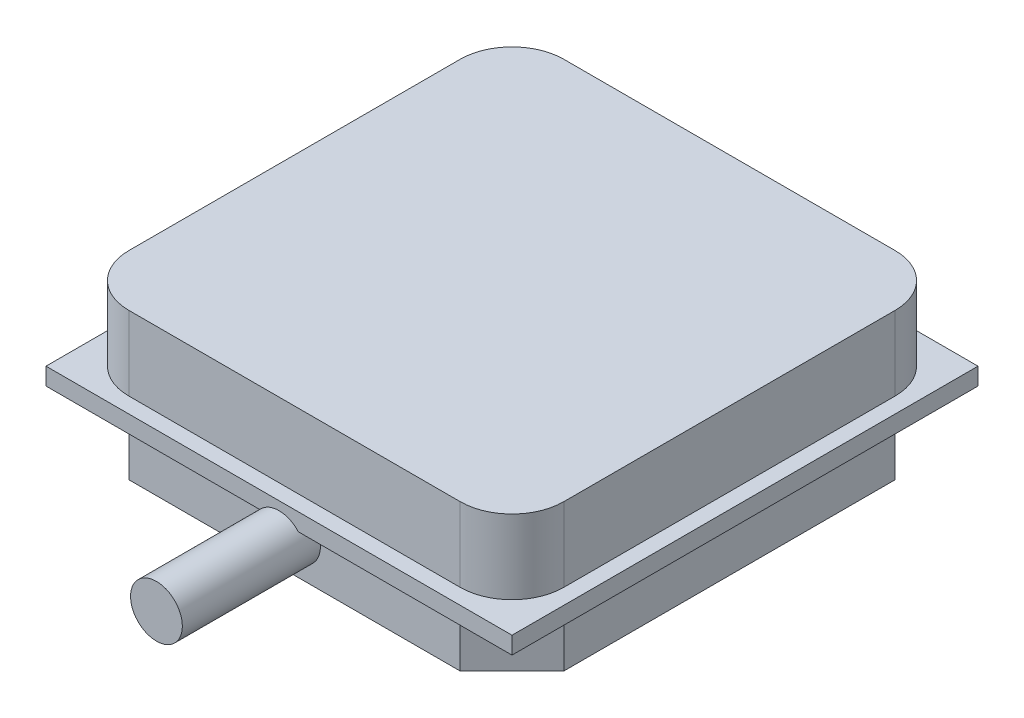
from build123d import *

# Parameters (mm, degrees)
SKETCH1_W           = 27
SKETCH1_H           = 27
BOSS_EXTRUDE1_DEPTH = 1
BOSS_EXTRUDE2_DEPTH = 4.3
BOSS_EXTRUDE3_DEPTH = 3.2
SKETCH4_R           = 1.5
BOSS_EXTRUDE5_DEPTH = 8


with BuildPart() as part:
    # Sketch1 → Boss-Extrude1 (new body)
    with BuildSketch(Plane(origin=(0, 0, 0), x_dir=(1, 0, 0), z_dir=(0, 1, 0))):
        with Locations((13.5, 13.5)):
            Rectangle(SKETCH1_W, SKETCH1_H)
    extrude(amount=BOSS_EXTRUDE1_DEPTH)

    # Sketch2 → Boss-Extrude2 (add)
    with BuildSketch(Plane(origin=(0, 1, 0), x_dir=(1, 0, 0), z_dir=(0, 1, 0))):
        with BuildLine():
            Line((3.9, 26.1), (23.1, 26.1))
            ThreePointArc((23.1, 26.1), (25.221320344, 25.221320344), (26.1, 23.1))
            Line((26.1, 23.1), (26.1, 3.9))
            ThreePointArc((26.1, 3.9), (25.221320344, 1.778679656), (23.1, 0.9))
            Line((23.1, 0.9), (3.9, 0.9))
            ThreePointArc((3.9, 0.9), (1.778679656, 1.778679656), (0.9, 3.9))
            Line((0.9, 3.9), (0.9, 23.1))
            ThreePointArc((0.9, 23.1), (1.778679656, 25.221320344), (3.9, 26.1))
        make_face()
    extrude(amount=BOSS_EXTRUDE2_DEPTH)

    # Sketch3 → Boss-Extrude3 (add)
    with BuildSketch(Plane.XZ):
        Polygon((3.9, -0.9), (23.1, -0.9), (26.1, -3.9), (26.1, -23.1), (23.1, -26.1), (3.9, -26.1), (0.9, -23.1), (0.9, -3.9), align=None)
    extrude(amount=BOSS_EXTRUDE3_DEPTH)

    # Sketch4 → Boss-Extrude5 (add)
    with BuildSketch(Plane.XY.offset(-0.9)):
        with Locations((13.5, -1)):
            Circle(SKETCH4_R)
    extrude(amount=BOSS_EXTRUDE5_DEPTH)


solid = part.part
